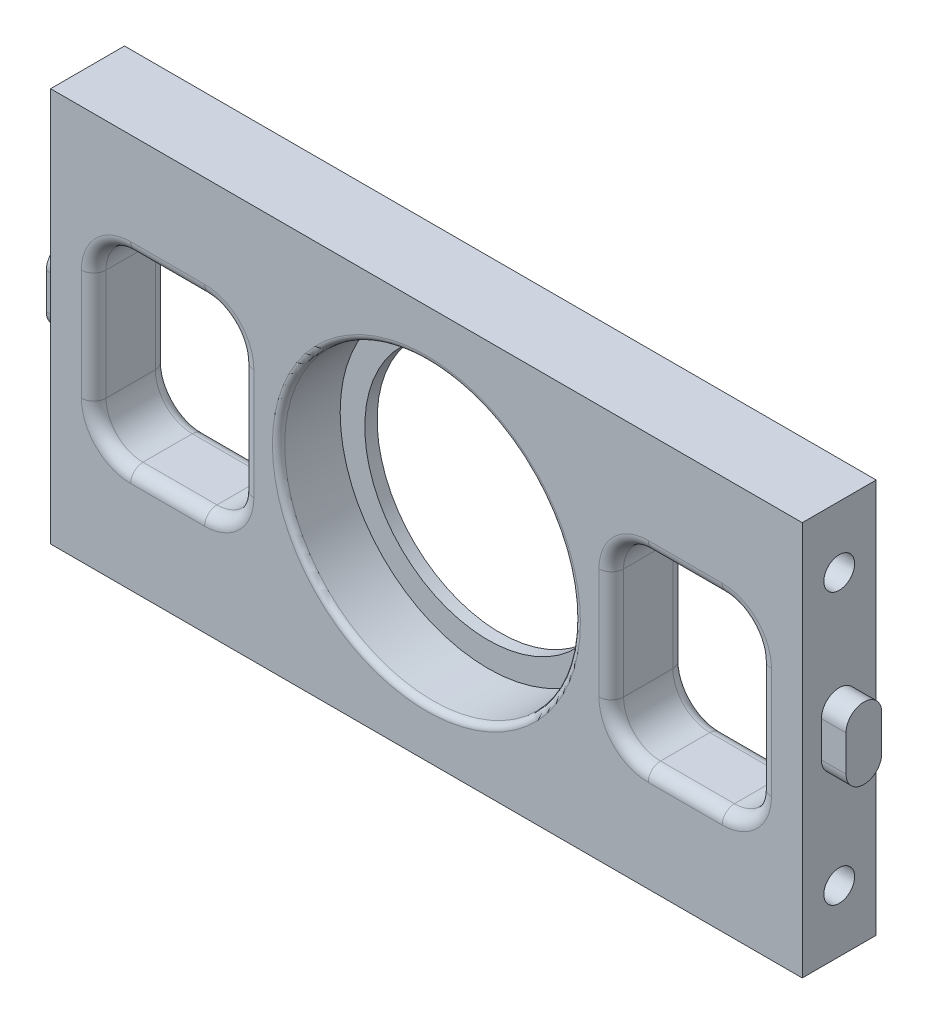
from build123d import *

# Parameters (mm, degrees)
SKETCH_1_W           = 61
SKETCH_1_H           = 32
EXTRUDE_1_DEPTH      = 6
SKETCH_2_R           = 10
CUT_EXTRUDE_13_DEPTH = 6
SKETCH_4_R           = 12
CUT_EXTRUDE_14_DEPTH = 5
CUT_EXTRUDE_16_DEPTH = 6
EXTRUDE_12_DEPTH     = 2
EXTRUDE_13_DEPTH     = 2
SKETCH_10_R          = 1.25
CUT_EXTRUDE_18_DEPTH = 15
SKETCH_11_R          = 1.25
CUT_EXTRUDE_19_DEPTH = 15
FILLET_1_R           = 1
FILLET_2_R           = 0.5


with BuildPart() as part:
    # Эскиз1 → Бобышка-Вытянуть1 (new body)
    with BuildSketch(Plane.XY):
        Rectangle(SKETCH_1_W, SKETCH_1_H)
    extrude(amount=EXTRUDE_1_DEPTH)

    # Эскиз2 → Вырез-Вытянуть13 (cut)
    with BuildSketch(Plane.XY.offset(6)):
        Circle(SKETCH_2_R)
    extrude(amount=-CUT_EXTRUDE_13_DEPTH, mode=Mode.SUBTRACT)

    # Эскиз4 → Вырез-Вытянуть14 (cut)
    with BuildSketch(Plane.XY.offset(6)):
        Circle(SKETCH_4_R)
    extrude(amount=-CUT_EXTRUDE_14_DEPTH, mode=Mode.SUBTRACT)

    # Эскиз5 → Вырез-Вытянуть16 (cut)
    with BuildSketch(Plane.XY.offset(6)):
        with BuildLine():
            Line((-18, -7.5), (-24, -7.5))
            ThreePointArc((-24, -7.5), (-26.121320344, -6.621320344), (-27, -4.5))
            Line((-27, -4.5), (-27, 4.5))
            ThreePointArc((-27, 4.5), (-26.121320344, 6.621320344), (-24, 7.5))
            Line((-24, 7.5), (-18, 7.5))
            ThreePointArc((-18, 7.5), (-15.878679656, 6.621320344), (-15, 4.5))
            Line((-15, 4.5), (-15, -4.5))
            ThreePointArc((-15, -4.5), (-15.878679656, -6.621320344), (-18, -7.5))
        make_face()
        with BuildLine():
            Line((18, 7.5), (24, 7.5))
            ThreePointArc((24, 7.5), (26.121320344, 6.621320344), (27, 4.5))
            Line((27, 4.5), (27, -4.5))
            ThreePointArc((27, -4.5), (26.121320344, -6.621320344), (24, -7.5))
            Line((24, -7.5), (18, -7.5))
            ThreePointArc((18, -7.5), (15.878679656, -6.621320344), (15, -4.5))
            Line((15, -4.5), (15, 4.5))
            ThreePointArc((15, 4.5), (15.878679656, 6.621320344), (18, 7.5))
        make_face()
    extrude(amount=-CUT_EXTRUDE_16_DEPTH, mode=Mode.SUBTRACT)

    # Эскиз8 → Бобышка-Вытянуть12 (add)
    with BuildSketch(Plane.ZY.offset(30.5)):
        with BuildLine():
            Line((1.45, -1.5), (1.45, 1.4))
            ThreePointArc((1.45, 1.4), (2.9, 2.85), (4.35, 1.4))
            Line((4.35, 1.4), (4.35, -1.5))
            ThreePointArc((4.35, -1.5), (2.9, -2.95), (1.45, -1.5))
        make_face()
    extrude(amount=EXTRUDE_12_DEPTH)

    # Эскиз9 → Бобышка-Вытянуть13 (add)
    with BuildSketch(Plane(origin=(30.5, 0, 0), x_dir=(0, 0, -1), z_dir=(1, 0, 0))):
        with BuildLine():
            Line((-1.55, 1.45), (-1.55, -1.45))
            ThreePointArc((-1.55, -1.45), (-3, -2.9), (-4.45, -1.45))
            Line((-4.45, -1.45), (-4.45, 1.45))
            ThreePointArc((-4.45, 1.45), (-3, 2.9), (-1.55, 1.45))
        make_face()
    extrude(amount=EXTRUDE_13_DEPTH)

    # Эскиз10 → Вырез-Вытянуть18 (cut)
    with BuildSketch(Plane.ZY.offset(30.5)):
        with Locations(Location((3, 11, 0), (0, 0, 90))):  # turned: the seam where the file's is
            Circle(SKETCH_10_R)
        with Locations(Location((3, -11, 0), (0, 0, 270))):  # turned: the seam where the file's is
            Circle(SKETCH_10_R)
    extrude(amount=-CUT_EXTRUDE_18_DEPTH, mode=Mode.SUBTRACT)

    # Эскиз11 → Вырез-Вытянуть19 (cut)
    with BuildSketch(Plane(origin=(30.5, 0, 0), x_dir=(0, 0, -1), z_dir=(1, 0, 0))):
        with Locations(Location((-3, 11, 0), (0, 0, 90))):  # turned: the seam where the file's is
            Circle(SKETCH_11_R)
        with Locations(Location((-3, -11, 0), (0, 0, 270))):  # turned: the seam where the file's is
            Circle(SKETCH_11_R)
    extrude(amount=-CUT_EXTRUDE_19_DEPTH, mode=Mode.SUBTRACT)

    # Скругление1
    fillet_1_edges = [part.edges().sort_by_distance(p)[0] for p in [
        (21, 7.5, 6),
        (26.121320344, 6.621320344, 0),
        (27, 0, 6),
        (26.121320344, -6.621320344, 6),
        (21, -7.5, 0),
        (15.878679656, -6.621320344, 6),
        (15, 0, 0),
        (15.878679656, 6.621320344, 0),
        (21, 7.5, 0),
        (27, 0, 0),
        (26.121320344, -6.621320344, 0),
        (15.878679656, -6.621320344, 0),
        (15.878679656, 6.621320344, 6),
        (15, 0, 6),
        (21, -7.5, 6),
        (26.121320344, 6.621320344, 6),
        (-21, 7.5, 0),
        (-15.878679656, 6.621320344, 0),
        (-15, 0, 0),
        (-15.878679656, -6.621320344, 6),
        (-21, -7.5, 6),
        (-26.121320344, -6.621320344, 0),
        (-27, 0, 6),
        (-26.121320344, 6.621320344, 0),
        (-15.878679656, -6.621320344, 0),
        (-21, -7.5, 0),
        (-27, 0, 0),
        (-21, 7.5, 6),
        (-26.121320344, 6.621320344, 6),
        (-26.121320344, -6.621320344, 6),
        (-15, 0, 6),
        (-15.878679656, 6.621320344, 6),
    ]]
    fillet(fillet_1_edges, radius=FILLET_1_R)

    # Скругление2
    fillet_2_edges = [part.edges().sort_by_distance(p)[0] for p in [
        (-12, 0, 6),
    ]]
    fillet(fillet_2_edges, radius=FILLET_2_R)


solid = part.part
